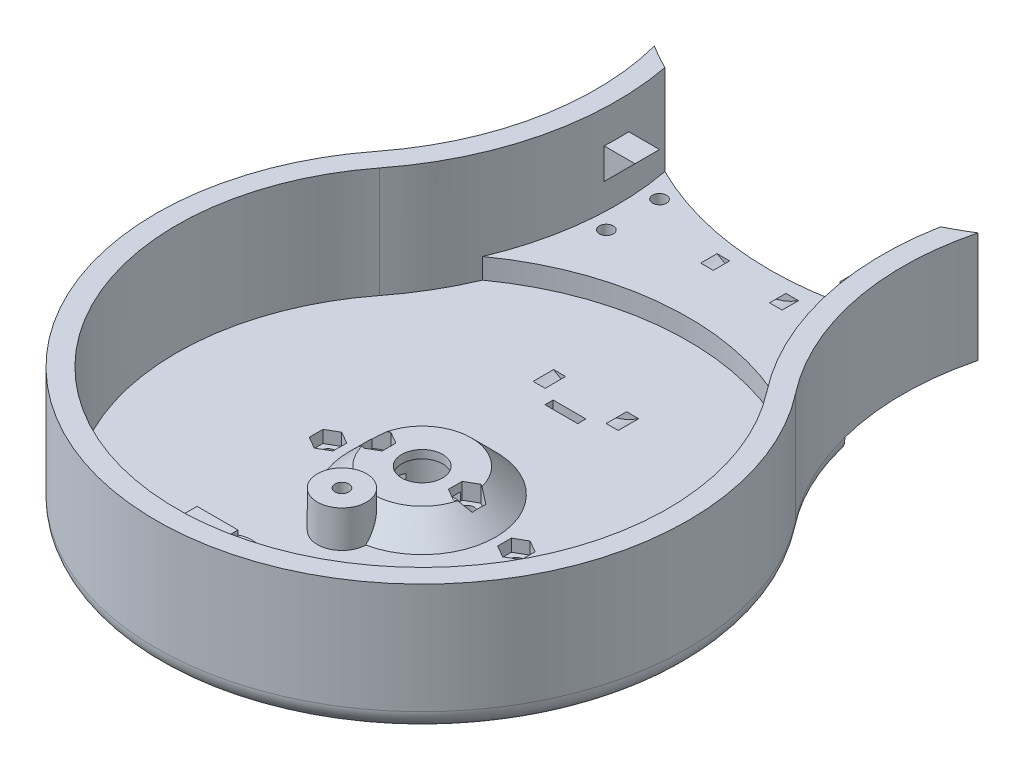
from build123d import *

# Parameters (mm, degrees)
SALIENTE_EXTRUIR1_DEPTH      = 32
CORTAR_EXTRUIR1_DEPTH        = 27
SALIENTE_EXTRUIR2_DEPTH      = 20
CROQUIS4_R                   = 1.7
CORTAR_EXTRUIR2_DEPTH        = 16
CORTAR_EXTRUIR3_DEPTH        = 1.5
CROQUIS7_R                   = 5
CORTAR_EXTRUIR4_DEPTH        = 11
CROQUIS8_R                   = 8.2
CORTAR_EXTRUIR5_DEPTH        = 9
CROQUIS9_W                   = 30.6
CROQUIS9_H                   = 7
CORTAR_EXTRUIR6_DEPTH        = 4
CROQUIS10_R                  = 1.7
CORTAR_EXTRUIR7_DEPTH        = 16
CORTAR_EXTRUIR8_DEPTH        = 4
CROQUIS12_W                  = 5
CROQUIS12_H                  = 1.5
SALIENTE_EXTRUIR3_DEPTH      = 5
CROQUIS14_W                  = 4
CROQUIS14_H                  = 1.5
CROQUIS15_R                  = 1.7
CORTAR_EXTRUIR9_DEPTH        = 28
CROQUIS16_R                  = 2.95
CORTAR_EXTRUIR10_DEPTH       = 2.9
SALIENTE_EXTRUIR4_DEPTH      = 3
SALIENTE_EXTRUIR4_DEPTH_BACK = 3
CROQUIS18_R                  = 6
CROQUIS18_R_2                = 1.7
SALIENTE_EXTRUIR5_DEPTH      = 9
CORTAR_EXTRUIR11_DEPTH       = 1.5
MATRIZL1_COUNT               = 2
MATRIZL1_PITCH               = 28
MATRIZC1_COUNT               = 2
MATRIZC1_COPY_1_SKETCH_R     = 6
MATRIZC1_COPY_1_SKETCH_R_2   = 1.7
MATRIZC1_COPY_1_DEPTH        = 9
MATRIZC1_COPY_2_DEPTH        = 1.5
CROQUIS20_R                  = 4.2
CORTAR_EXTRUIR12_DEPTH       = 1.1
REDONDEO1_R                  = 5
SALIENTE_EXTRUIR6_DEPTH      = 5
CROQUIS22_R                  = 75
CORTAR_EXTRUIR13_DEPTH       = 54
CORTAR_EXTRUIR14_DEPTH       = 5
CROQUIS24_R                  = 1.7
CORTAR_EXTRUIR15_DEPTH       = 10
CORTAR_EXTRUIR16_DEPTH       = 3
CROQUIS26_W                  = 8
CROQUIS26_H                  = 2
CORTAR_EXTRUIR17_DEPTH       = 12


with BuildPart() as part:
    # Croquis1 → Saliente-Extruir1 (new body)
    with BuildSketch(Plane(origin=(0, 0, 0), x_dir=(1, 0, 0), z_dir=(0, 1, 0))):
        with BuildLine():
            ThreePointArc((51.23475383, 120), (0, 225), (-51.23475383, 120))
            ThreePointArc((-51.23475383, 120), (-37.46950766, 80), (-51.23475383, 40))
            ThreePointArc((-51.23475383, 40), (0, -65), (51.23475383, 40))
            ThreePointArc((51.23475383, 40), (37.46950766, 80), (51.23475383, 120))
        make_face()
    extrude(amount=SALIENTE_EXTRUIR1_DEPTH)

    # Croquis2 → Cortar-Extruir1 (cut)
    with BuildSketch(Plane(origin=(0, 32, 0), x_dir=(1, 0, 0), z_dir=(0, 1, 0))):
        with BuildLine():
            ThreePointArc((47.29361892, 123.076923077), (32.46950766, 80), (47.29361892, 36.923076923))
            ThreePointArc((47.29361892, 36.923076923), (0, -60), (-47.29361892, 36.923076923))
            ThreePointArc((-47.29361892, 36.923076923), (-32.46950766, 80), (-47.29361892, 123.076923077))
            ThreePointArc((-47.29361892, 123.076923077), (0, 220), (47.29361892, 123.076923077))
        make_face()
    extrude(amount=-CORTAR_EXTRUIR1_DEPTH, mode=Mode.SUBTRACT)

    # Croquis3 → Saliente-Extruir2 (add)
    with BuildSketch(Plane(origin=(0, 5, 0), x_dir=(1, 0, 0), z_dir=(0, 1, 0))):
        with BuildLine():
            Line((-5, -50), (5, -50))
            Line((5, -50), (5, -59.791303716))
            ThreePointArc((5, -59.791303716), (0, -60), (-5, -59.791303716))
            Line((-5, -59.791303716), (-5, -50))
        make_face()
    saliente_extruir2 = extrude(amount=SALIENTE_EXTRUIR2_DEPTH)

    # Croquis4 → Cortar-Extruir2 (cut)
    with BuildSketch(Plane(origin=(0, 25, 0), x_dir=(1, 0, 0), z_dir=(0, 1, 0))):
        with Locations((0, -55)):
            Circle(CROQUIS4_R)
    cortar_extruir2 = extrude(amount=-CORTAR_EXTRUIR2_DEPTH, mode=Mode.SUBTRACT)

    # Croquis5 → Cortar-Extruir3 (cut, symmetric)
    with BuildSketch(Plane(origin=(0, 20.5, 0), x_dir=(1, 0, 0), z_dir=(0, 1, 0))):
        Polygon((-2.901185103, -53.325), (-2.901185103, -46.675), (2.901185103, -46.675), (2.901185103, -53.325), (2.901185103, -56.675), (0, -58.35), (-2.901185103, -56.675), align=None)
    cortar_extruir3 = extrude(amount=CORTAR_EXTRUIR3_DEPTH, both=True, mode=Mode.SUBTRACT)

    # Croquis6 → Revoluci_n1 (revolve)
    with BuildSketch(Plane.XY):
        Polygon((0, 11), (0, 5), (18, 5), (12, 11), align=None)
    revoluci_n1 = revolve(axis=Axis((0, 11, 0), (0, -1, 0)))

    # Croquis7 → Cortar-Extruir4 (cut)
    with BuildSketch(Plane(origin=(0, 11, 0), x_dir=(1, 0, 0), z_dir=(0, 1, 0))):
        Circle(CROQUIS7_R)
    cortar_extruir4 = extrude(amount=-CORTAR_EXTRUIR4_DEPTH, mode=Mode.SUBTRACT)

    # Croquis8 → Cortar-Extruir5 (cut)
    with BuildSketch(Plane.XZ):
        Circle(CROQUIS8_R)
    cortar_extruir5 = extrude(amount=-CORTAR_EXTRUIR5_DEPTH, mode=Mode.SUBTRACT)

    # Croquis9 → Cortar-Extruir6 (cut)
    with BuildSketch(Plane.XZ):
        Rectangle(CROQUIS9_W, CROQUIS9_H)
    cortar_extruir6 = extrude(amount=-CORTAR_EXTRUIR6_DEPTH, mode=Mode.SUBTRACT)

    # Croquis10 → Cortar-Extruir7 (cut)
    with BuildSketch(Plane.XZ.offset(-4)):
        with Locations((-11, 0)):
            Circle(CROQUIS10_R)
        with Locations((11, 0)):
            Circle(CROQUIS10_R)
    cortar_extruir7 = extrude(amount=-CORTAR_EXTRUIR7_DEPTH, mode=Mode.SUBTRACT)

    # Croquis11 → Cortar-Extruir8 (cut)
    with BuildSketch(Plane(origin=(0, 11, 0), x_dir=(1, 0, 0), z_dir=(0, 1, 0))):
        Polygon((11, 3.35), (8.098814897, 1.675), (8.098814897, -1.675), (11, -3.35), (13.901185103, -1.675), (13.901185103, 1.675), align=None)
        Polygon((-11, 3.35), (-13.901185103, 1.675), (-13.901185103, -1.675), (-11, -3.35), (-8.098814897, -1.675), (-8.098814897, 1.675), align=None)
    cortar_extruir8 = extrude(amount=-CORTAR_EXTRUIR8_DEPTH, mode=Mode.SUBTRACT)

    # Croquis12 → Cortar-Revoluci_n1 (revolve, cut)
    with BuildSketch(Plane(origin=(0, 0, 0), x_dir=(0, 0, -1), z_dir=(1, 0, 0))):
        with Locations((40, 2.5)):
            Rectangle(CROQUIS12_W, CROQUIS12_H)
    cortar_revoluci_n1 = revolve(axis=Axis((0, 20, -15.980405029), (0, 0, -1)), mode=Mode.SUBTRACT)

    # Simetr_a1: Saliente-Extruir2, Cortar-Extruir2, Cortar-Extruir3, Revoluci_n1, Cortar-Extruir4, Cortar-Extruir5, Cortar-Extruir6, Cortar-Extruir7, Cortar-Extruir8, Cortar-Revoluci_n1 across plane
    add(saliente_extruir2.mirror(Plane.XY.offset(-80)))
    add(cortar_extruir2.mirror(Plane.XY.offset(-80)), mode=Mode.SUBTRACT)
    add(cortar_extruir3.mirror(Plane.XY.offset(-80)), mode=Mode.SUBTRACT)
    add(revoluci_n1.mirror(Plane.XY.offset(-80)))
    add(cortar_extruir4.mirror(Plane.XY.offset(-80)), mode=Mode.SUBTRACT)
    add(cortar_extruir5.mirror(Plane.XY.offset(-80)), mode=Mode.SUBTRACT)
    add(cortar_extruir6.mirror(Plane.XY.offset(-80)), mode=Mode.SUBTRACT)
    add(cortar_extruir7.mirror(Plane.XY.offset(-80)), mode=Mode.SUBTRACT)
    add(cortar_extruir8.mirror(Plane.XY.offset(-80)), mode=Mode.SUBTRACT)
    add(cortar_revoluci_n1.mirror(Plane.XY.offset(-80)), mode=Mode.SUBTRACT)

    # Croquis13 → Saliente-Extruir3 (add)
    with BuildSketch(Plane(origin=(0, 5, 0), x_dir=(1, 0, 0), z_dir=(0, 1, 0))):
        with BuildLine():
            ThreePointArc((-33.685420375, 67.009644486), (-32.46950766, 80), (-33.685420375, 92.990355514))
            ThreePointArc((-33.685420375, 92.990355514), (0, 85), (33.685420375, 92.990355514))
            ThreePointArc((33.685420375, 92.990355514), (32.46950766, 80), (33.685420375, 67.009644486))
            ThreePointArc((33.685420375, 67.009644486), (0, 75), (-33.685420375, 67.009644486))
        make_face()
    extrude(amount=SALIENTE_EXTRUIR3_DEPTH)

    # Croquis14 → Cortar-Revoluci_n2 (revolve, cut)
    with BuildSketch(Plane(origin=(0, 0, 0), x_dir=(0, 0, -1), z_dir=(1, 0, 0))):
        with Locations((80, 7.75)):
            Rectangle(CROQUIS14_W, CROQUIS14_H)
    revolve(axis=Axis((0, 25, -45.111701589), (0, 0, -1)), mode=Mode.SUBTRACT)

    # Croquis15 → Cortar-Extruir9 (cut)
    with BuildSketch(Plane(origin=(0, 10, 0), x_dir=(1, 0, 0), z_dir=(0, 1, 0))):
        with Locations((-28.5, 86.5)):
            Circle(CROQUIS15_R)
        with Locations((-28.5, 73.5)):
            Circle(CROQUIS15_R)
        with Locations((28.5, 86.5)):
            Circle(CROQUIS15_R)
        with Locations((28.5, 73.5)):
            Circle(CROQUIS15_R)
    extrude(amount=-CORTAR_EXTRUIR9_DEPTH, mode=Mode.SUBTRACT)

    # Croquis16 → Cortar-Extruir10 (cut)
    with BuildSketch(Plane.XZ):
        with Locations((-28.5, -73.5)):
            Circle(CROQUIS16_R)
        with Locations((-28.5, -86.5)):
            Circle(CROQUIS16_R)
        with Locations((28.5, -86.5)):
            Circle(CROQUIS16_R)
        with Locations((28.5, -73.5)):
            Circle(CROQUIS16_R)
    extrude(amount=-CORTAR_EXTRUIR10_DEPTH, mode=Mode.SUBTRACT)

    # Croquis17 → Saliente-Extruir4 (add, two sides)
    with BuildSketch(Plane.XY.offset(-80)) as saliente_extruir4_sk:
        Polygon((-35, 24), (-35, 14), (-25, 24), align=None)
        Polygon((25, 24), (35, 24), (35, 14), align=None)
    extrude(amount=SALIENTE_EXTRUIR4_DEPTH)
    extrude(saliente_extruir4_sk.sketch, amount=-SALIENTE_EXTRUIR4_DEPTH_BACK)

    # Croquis18 → Saliente-Extruir5 (add)
    with BuildSketch(Plane(origin=(0, 5, 0), x_dir=(1, 0, 0), z_dir=(0, 1, 0))):
        with Locations((-2.2, -45.4)):
            Circle(CROQUIS18_R)
        with Locations((-2.2, -45.4)):
            Circle(CROQUIS18_R_2, mode=Mode.SUBTRACT)
    saliente_extruir5 = extrude(amount=SALIENTE_EXTRUIR5_DEPTH)

    # Croquis19 → Cortar-Extruir11 (cut, symmetric)
    with BuildSketch(Plane(origin=(0, 9.5, 0), x_dir=(1, 0, 0), z_dir=(0, 1, 0))):
        Polygon((-3.875, -42.498814897), (-10.525, -42.498814897), (-10.525, -48.301185103), (-3.875, -48.301185103), (-0.525, -48.301185103), (1.15, -45.4), (-0.525, -42.498814897), align=None)
    cortar_extruir11 = extrude(amount=CORTAR_EXTRUIR11_DEPTH, both=True, mode=Mode.SUBTRACT)

    # MatrizL1: Saliente-Extruir5, Cortar-Extruir11 ×2
    with Locations(*[(0, 0, -i * MATRIZL1_PITCH) for i in range(1, MATRIZL1_COUNT)]):
        add(saliente_extruir5)
        add(cortar_extruir11, mode=Mode.SUBTRACT)

    # MatrizC1: Saliente-Extruir5, Cortar-Extruir11 ×2 about axis
    matrizc1_axis = Axis((0, 0, -80), (0, 1, 0))
    for i in range(1, MATRIZC1_COUNT):
        add(saliente_extruir5.rotate(matrizc1_axis, i * 360 / MATRIZC1_COUNT))
        add(cortar_extruir11.rotate(matrizc1_axis, i * 360 / MATRIZC1_COUNT), mode=Mode.SUBTRACT)

    # MatrizC1 copy 1 sketch → MatrizC1 copy 1 (add)
    with BuildSketch(Plane(origin=(0, 5, -132), x_dir=(-1, 0, 0), z_dir=(0, 1, 0))):
        with Locations((-2.2, -45.4)):
            Circle(MATRIZC1_COPY_1_SKETCH_R)
        with Locations((-2.2, -45.4)):
            Circle(MATRIZC1_COPY_1_SKETCH_R_2, mode=Mode.SUBTRACT)
    extrude(amount=MATRIZC1_COPY_1_DEPTH)

    # MatrizC1 copy 2 sketch → MatrizC1 copy 2 (cut, symmetric)
    with BuildSketch(Plane(origin=(0, 9.5, -132), x_dir=(-1, 0, 0), z_dir=(0, 1, 0))):
        Polygon((-3.875, -42.498814897), (-10.525, -42.498814897), (-10.525, -48.301185103), (-3.875, -48.301185103), (-0.525, -48.301185103), (1.15, -45.4), (-0.525, -42.498814897), align=None)
    extrude(amount=MATRIZC1_COPY_2_DEPTH, both=True, mode=Mode.SUBTRACT)

    # Croquis20 → Cortar-Extruir12 (cut)
    with BuildSketch(Plane.XZ):
        with Locations((0, 54.5)):
            Circle(CROQUIS20_R)
        with Locations((0, -80)):
            Circle(CROQUIS20_R)
        with Locations((0, -214.5)):
            Circle(CROQUIS20_R)
    extrude(amount=-CORTAR_EXTRUIR12_DEPTH, mode=Mode.SUBTRACT)

    # Redondeo1
    redondeo1_edges = [part.edges().sort_by_distance(p)[0] for p in [
        (0, 0, 65),
        (-37.46950766, 0, -80),
        (0, 0, -225),
        (37.46950766, 0, -80),
    ]]
    fillet(redondeo1_edges, radius=REDONDEO1_R)

    # Croquis21 → Saliente-Extruir6 (add)
    with BuildSketch(Plane(origin=(0, 5, 0), x_dir=(1, 0, 0), z_dir=(0, 1, 0))):
        with BuildLine():
            ThreePointArc((33.685420375, 67.009644486), (35.459922204, 59.758570776), (37.996513473, 52.737699645))
            ThreePointArc((37.996513473, 52.737699645), (0, 65), (-37.996513473, 52.737699645))
            ThreePointArc((-37.996513473, 52.737699645), (-35.459922204, 59.758570776), (-33.685420375, 67.009644486))
            ThreePointArc((-33.685420375, 67.009644486), (0, 75), (33.685420375, 67.009644486))
        make_face()
    extrude(amount=SALIENTE_EXTRUIR6_DEPTH)

    # Croquis22 → Cortar-Extruir13 (cut)
    with BuildSketch(Plane(origin=(0, 32, 0), x_dir=(1, 0, 0), z_dir=(0, 1, 0))):
        with Locations((0, 160)):
            Circle(CROQUIS22_R)
    extrude(amount=-CORTAR_EXTRUIR13_DEPTH, mode=Mode.SUBTRACT)

    # Croquis23 → Cortar-Extruir14 (cut)
    with BuildSketch(Plane.XZ):
        with BuildLine():
            Line((-50, -55.901699437), (-50, -115.901699437))
            Line((-50, -115.901699437), (50, -115.901699437))
            Line((50, -115.901699437), (50, -55.901699437))
            ThreePointArc((50, -55.901699437), (0, -75), (-50, -55.901699437))
        make_face()
    extrude(amount=-CORTAR_EXTRUIR14_DEPTH, mode=Mode.SUBTRACT)

    # Croquis24 → Cortar-Extruir15 (cut)
    with BuildSketch(Plane.XZ):
        with Locations((-23.0125, 0)):
            Circle(CROQUIS24_R)
        with Locations((23.0125, 0)):
            Circle(CROQUIS24_R)
    extrude(amount=-CORTAR_EXTRUIR15_DEPTH, mode=Mode.SUBTRACT)

    # Croquis25 → Cortar-Extruir16 (cut)
    with BuildSketch(Plane(origin=(0, 5, 0), x_dir=(1, 0, 0), z_dir=(0, 1, 0))):
        Polygon((-23.0125, 3.35), (-25.913685103, 1.675), (-25.913685103, -1.675), (-23.0125, -3.35), (-20.111314897, -1.675), (-20.111314897, 1.675), align=None)
        Polygon((23.0125, 3.35), (20.111314897, 1.675), (20.111314897, -1.675), (23.0125, -3.35), (25.913685103, -1.675), (25.913685103, 1.675), align=None)
    extrude(amount=-CORTAR_EXTRUIR16_DEPTH, mode=Mode.SUBTRACT)

    # Croquis26 → Cortar-Extruir17 (cut)
    with BuildSketch(Plane.XZ):
        with Locations((0, -35)):
            Rectangle(CROQUIS26_W, CROQUIS26_H)
    extrude(amount=-CORTAR_EXTRUIR17_DEPTH, mode=Mode.SUBTRACT)


solid = part.part
